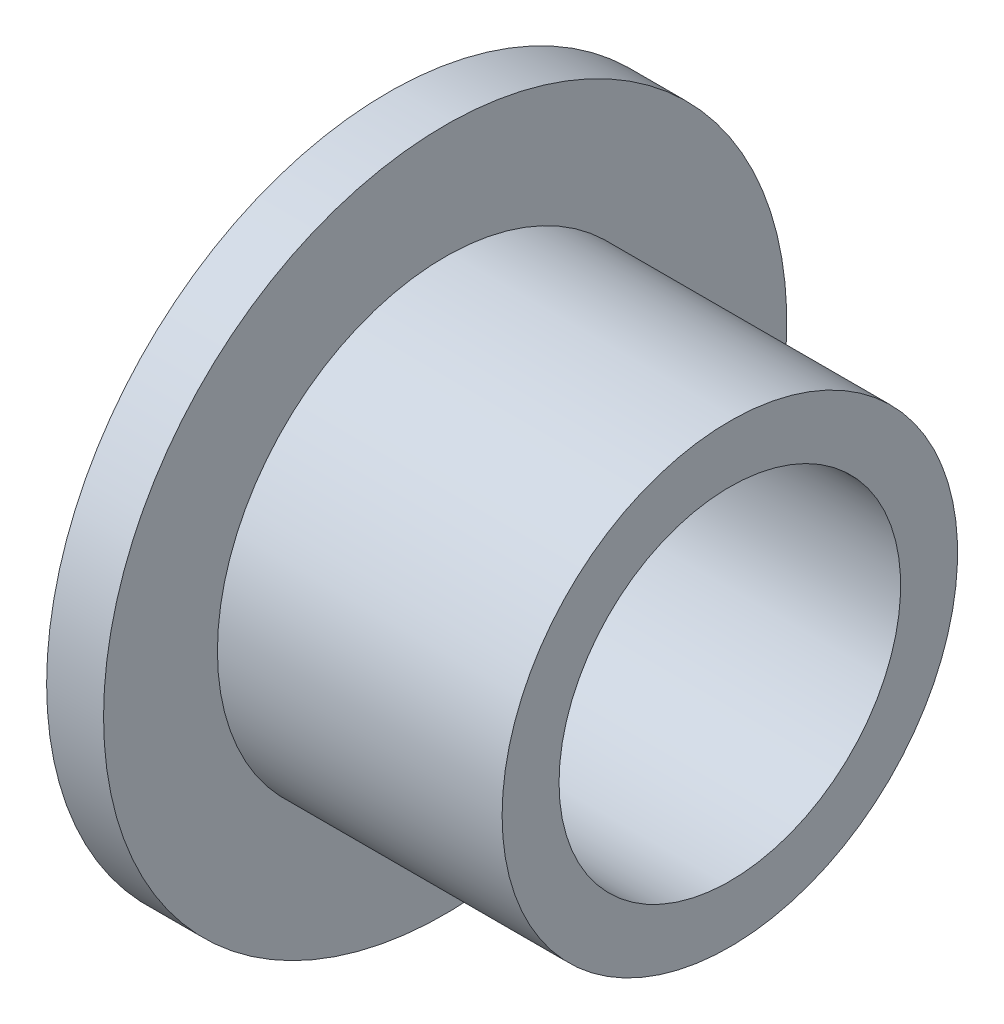
from build123d import *


with BuildPart() as part:
    # Skizze1 → Rotation-Dünn1 (revolve)
    with BuildSketch(Plane.XY):
        Polygon((0, 6), (0, 3), (6, 3), (6, 4), (1, 4), (1, 6), align=None)
    revolve(axis=Axis((0, 0, 0), (1, 0, 0)))


solid = part.part
